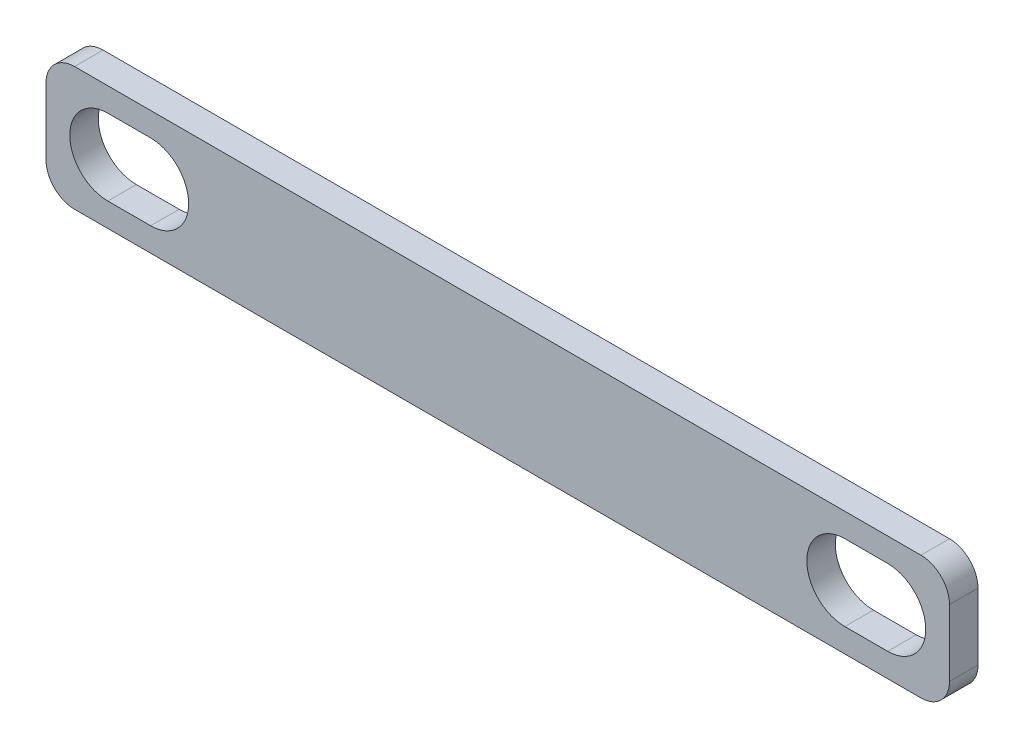
from build123d import *

# Parameters (mm, degrees)
SKETCH_1_W          = 95
SKETCH_1_H          = 13
EXTRUDE_1_DEPTH     = 3
SKETCH_2_R          = 4
CUT_EXTRUDE_1_DEPTH = 3
FILLET_1_R          = 3
SKETCH_3_R          = 4
CUT_EXTRUDE_2_DEPTH = 3
SKETCH_4_W          = 4.5
SKETCH_4_H          = 8
CUT_EXTRUDE_3_DEPTH = 3


with BuildPart() as part:
    # ｽｹｯﾁ1 → ﾎﾞｽ - 押し出し1 (new body)
    with BuildSketch(Plane.XY):
        Rectangle(SKETCH_1_W, SKETCH_1_H)
    extrude(amount=EXTRUDE_1_DEPTH)

    # ｽｹｯﾁ2 → ｶｯﾄ - 押し出し1 (cut)
    with BuildSketch(Plane.XY.offset(3)):
        with Locations((41, 0)):
            Circle(SKETCH_2_R)
        with Locations((-41, 0)):
            Circle(SKETCH_2_R)
    extrude(amount=-CUT_EXTRUDE_1_DEPTH, mode=Mode.SUBTRACT)

    # ﾌｨﾚｯﾄ1
    fillet_1_edges = [part.edges().sort_by_distance(p)[0] for p in [
        (47.5, -6.5, 1.5),
        (-47.5, -6.5, 1.5),
        (-47.5, 6.5, 1.5),
        (47.5, 6.5, 1.5),
    ]]
    fillet(fillet_1_edges, radius=FILLET_1_R)

    # ｽｹｯﾁ3 → ｶｯﾄ - 押し出し2 (cut)
    with BuildSketch(Plane.XY.offset(3)):
        with Locations((36.5, 0)):
            Circle(SKETCH_3_R)
        with Locations((-36.5, 0)):
            Circle(SKETCH_3_R)
    extrude(amount=-CUT_EXTRUDE_2_DEPTH, mode=Mode.SUBTRACT)

    # ｽｹｯﾁ4 → ｶｯﾄ - 押し出し3 (cut)
    with BuildSketch(Plane.XY.offset(3)):
        with Locations((-38.75, 0)):
            Rectangle(SKETCH_4_W, SKETCH_4_H)
        with Locations((38.75, 0)):
            Rectangle(SKETCH_4_W, SKETCH_4_H)
    extrude(amount=-CUT_EXTRUDE_3_DEPTH, mode=Mode.SUBTRACT)


solid = part.part
